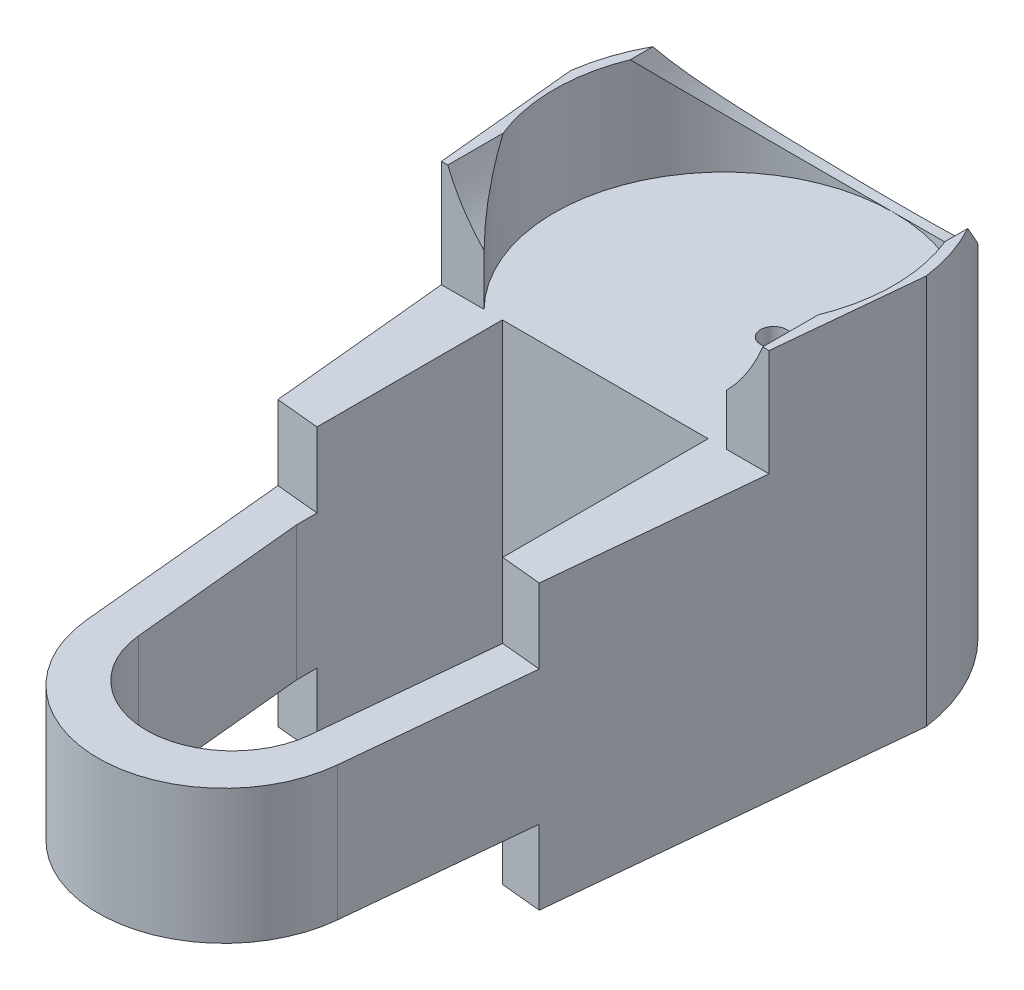
from build123d import *

# Parameters (mm, degrees)
SKETCH1_W                = 42.418
SKETCH1_H                = 0.006053875
SKETCH1_H_2              = 42.424053875
BOSS_EXTRUDE1_DEPTH      = 58.42
CUT_EXTRUDE3_DEPTH       = 68.58
SKETCH3_W                = 38.1
SKETCH3_H                = 15.367
SKETCH3_W_2              = 76.2
CUT_EXTRUDE4_DEPTH       = 77.078788463
BOSS_EXTRUDE6_DEPTH      = 3.302
BOSS_EXTRUDE6_DEPTH_BACK = 60
CUT_EXTRUDE9_DEPTH       = 106
SKETCH4_R                = 2.667
CUT_EXTRUDE6_DEPTH       = 106
CUT_EXTRUDE6_DEPTH_BACK  = 20
CUT_EXTRUDE13_DEPTH      = 106
SKETCH11_R               = 35
CUT_EXTRUDE15_DEPTH      = 106


with BuildPart() as part:
    # Sketch1 → Boss-Extrude1 (new body)
    with BuildSketch(Plane(origin=(0, 0, 0), x_dir=(1, 0, 0), z_dir=(0, 1, 0))):
        with BuildLine():
            ThreePointArc((36.658549334, 5.015053409), (0, 37), (-36.658549334, 5.015053409))
            Line((-36.658549334, 5.015053409), (-25.85615018, -105.598244919))
            ThreePointArc((-25.85615018, -105.598244919), (0, -129.052312238), (25.85615018, -105.598244919))
            Line((25.85615018, -105.598244919), (36.658549334, 5.015053409))
        make_face()
        with Locations((0, 21.205973063)):
            Rectangle(SKETCH1_W, SKETCH1_H, mode=Mode.SUBTRACT)
        with Locations((0, -21.212026937)):
            Rectangle(SKETCH1_W, SKETCH1_H, mode=Mode.SUBTRACT)
        with Locations((0, -45.723026938)):
            Rectangle(SKETCH1_W, SKETCH1_H_2, mode=Mode.SUBTRACT)
    extrude(amount=BOSS_EXTRUDE1_DEPTH)

    # Sketch2 → Cut-Extrude3 (cut)
    with BuildSketch(Plane(origin=(0, 58.42, 0), x_dir=(1, 0, 0), z_dir=(0, 1, 0))):
        with BuildLine():
            Line((-21.209, -66.935053875), (-17.681227978, -103.058371806))
            ThreePointArc((-17.681227978, -103.058371806), (0, -119.096981901), (17.681227978, -103.058371806))
            Line((17.681227978, -103.058371806), (21.209, -66.935053875))
            Line((21.209, -66.935053875), (-21.209, -66.935053875))
        make_face()
    extrude(amount=-CUT_EXTRUDE3_DEPTH, mode=Mode.SUBTRACT)

    # Sketch3 → Cut-Extrude4 (cut, through all)
    with BuildSketch(Plane(origin=(35.827089604, 0, 3.498842619), x_dir=(0.097196738, 0, -0.995265188), z_dir=(0.995265188, 0, 0.097196738))):
        with Locations((-121.635123595, 7.6835)):
            Rectangle(SKETCH3_W, SKETCH3_H)
        with Locations((-83.535123595, 7.6835)):
            Rectangle(SKETCH3_W, SKETCH3_H)
        with Locations((-102.585123595, 50.7365)):
            Rectangle(SKETCH3_W_2, SKETCH3_H)
    extrude(amount=-CUT_EXTRUDE4_DEPTH, mode=Mode.SUBTRACT)

    # Sketch7 → Boss-Extrude6 (add, two sides)
    with BuildSketch(Plane.XY.offset(21.209)) as boss_extrude6_sk:
        with BuildLine():
            Line((-34.93, 93.35), (-40.014696591, 94.207479888))
            Line((-40.014696591, 94.207479888), (-40.014696591, 55.40139672))
            Line((-40.014696591, 55.40139672), (41.480417685, 55.40139672))
            Line((41.480417685, 55.40139672), (41.480417685, 93.35))
            Line((41.480417685, 93.35), (34.93, 93.35))
            ThreePointArc((34.93, 93.35), (0, 58.42), (-34.93, 93.35))
        make_face()
    extrude(amount=BOSS_EXTRUDE6_DEPTH)
    extrude(boss_extrude6_sk.sketch, amount=-BOSS_EXTRUDE6_DEPTH_BACK)

    # Sketch9 → Cut-Extrude9 (cut)
    with BuildSketch(Plane.XZ):
        with BuildLine():
            Line((36.658549334, -5.015053409), (29.559345914, 67.678641264))
            Line((29.559345914, 67.678641264), (73.660631966, -15.324129582))
            Line((73.660631966, -15.324129582), (14.272065625, -84.211573711))
            Line((14.272065625, -84.211573711), (-60.028569558, -39.869360469))
            Line((-60.028569558, -39.869360469), (-30.128608249, 61.849567226))
            Line((-30.128608249, 61.849567226), (-36.658549334, -5.015053409))
            ThreePointArc((-36.658549334, -5.015053409), (0, -37), (36.658549334, -5.015053409))
        make_face()
    extrude(amount=-CUT_EXTRUDE9_DEPTH, mode=Mode.SUBTRACT)

    # Sketch4 → Cut-Extrude6 (cut, two sides)
    with BuildSketch(Plane(origin=(0, 58.42, 0), x_dir=(1, 0, 0), z_dir=(0, 1, 0))) as cut_extrude6_sk:
        with Locations((9.8, 0.389)):
            Circle(SKETCH4_R)
    extrude(amount=CUT_EXTRUDE6_DEPTH, mode=Mode.SUBTRACT)
    extrude(cut_extrude6_sk.sketch, amount=-CUT_EXTRUDE6_DEPTH_BACK, mode=Mode.SUBTRACT)

    # Sketch10 → Cut-Extrude13 (cut)
    with BuildSketch(Plane(origin=(35.827089604, 0, 3.498842619), x_dir=(0.097196738, 0, -0.995265188), z_dir=(0.995265188, 0, 0.097196738))):
        Polygon((-21.112119301, 84.442127612), (-21.112119301, 80.442127612), (1.82615742, 80.442127612), (48.352358454, 80.442127612), (47.215493026, 104.044705577), (-21.112119301, 100.753569315), align=None)
        Polygon((-34.412747442, 80.442127612), (-21.112119301, 80.442127612), (-21.112119301, 84.442127612), (-21.112119301, 100.753569315), (-34.412747442, 100.753569315), align=None)
    extrude(amount=-CUT_EXTRUDE13_DEPTH, mode=Mode.SUBTRACT)

    # Sketch11 → Cut-Extrude15 (cut)
    with BuildSketch(Plane(origin=(0, 58.42, 0), x_dir=(1, 0, 0), z_dir=(0, 1, 0))):
        Circle(SKETCH11_R)
    extrude(amount=CUT_EXTRUDE15_DEPTH, mode=Mode.SUBTRACT)


solid = part.part
